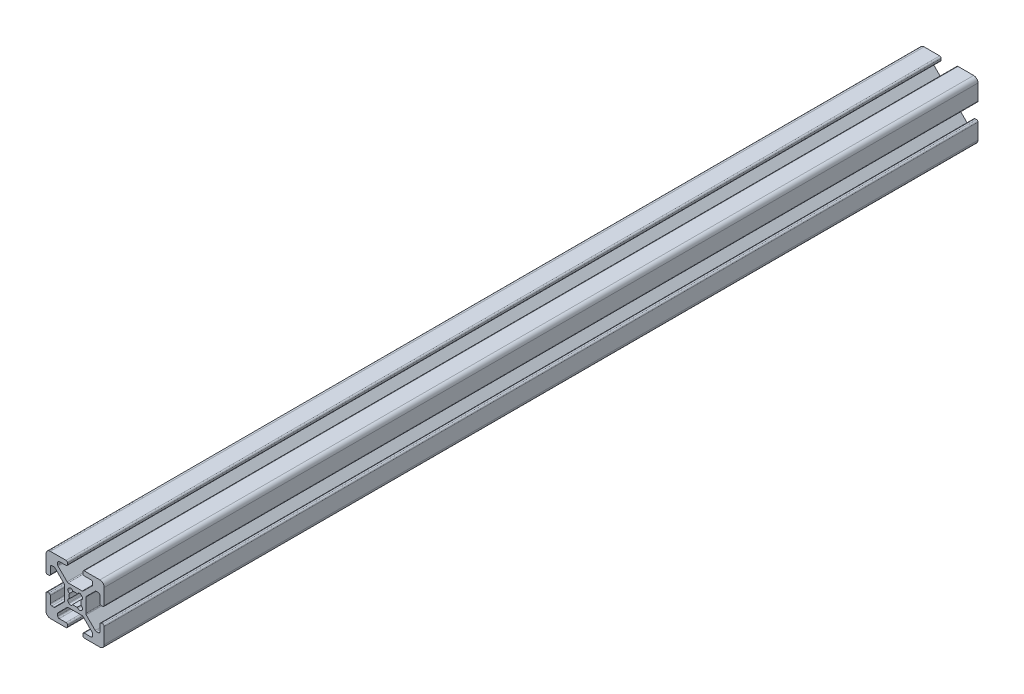
from build123d import *

# Parameters (mm, degrees)
EXTRUDE1_DEPTH = 300


with BuildPart() as part:
    # Sketch1 → Extrude1 (new body)
    with BuildSketch(Plane.XY):
        with BuildLine():
            Line((9.492, 2.63), (9.008, 2.63))
            ThreePointArc((9.008, 2.63), (8.648789755, 2.778789755), (8.5, 3.138))
            Line((8.5, 3.138), (8.5, 5.487))
            ThreePointArc((8.5, 5.487), (8.351210245, 5.846210245), (7.992, 5.995))
            Line((7.992, 5.995), (7.266080661, 5.995))
            ThreePointArc((7.266080661, 5.995), (7.071677478, 5.956330803), (6.906870417, 5.846210245))
            Line((6.906870417, 5.846210245), (3.803789755, 2.743129583))
            ThreePointArc((3.803789755, 2.743129583), (3.693669197, 2.578322522), (3.655, 2.383919339))
            Line((3.655, 2.383919339), (3.655, -2.383919339))
            ThreePointArc((3.655, -2.383919339), (3.693669197, -2.578322522), (3.803789755, -2.743129583))
            Line((3.803789755, -2.743129583), (6.906870417, -5.846210245))
            ThreePointArc((6.906870417, -5.846210245), (7.071677478, -5.956330803), (7.266080661, -5.995))
            Line((7.266080661, -5.995), (7.992, -5.995))
            ThreePointArc((7.992, -5.995), (8.351210245, -5.846210245), (8.5, -5.487))
            Line((8.5, -5.487), (8.5, -3.138))
            ThreePointArc((8.5, -3.138), (8.648789755, -2.778789755), (9.008, -2.63))
            Line((9.008, -2.63), (9.492, -2.63))
            ThreePointArc((9.492, -2.63), (9.851210245, -2.778789755), (10, -3.138))
            Line((10, -3.138), (10, -8.5))
            ThreePointArc((10, -8.5), (9.560660172, -9.560660172), (8.5, -10))
            Line((8.5, -10), (3.138, -10))
            ThreePointArc((3.138, -10), (2.778789755, -9.851210245), (2.63, -9.492))
            Line((2.63, -9.492), (2.63, -9.008))
            ThreePointArc((2.63, -9.008), (2.778789755, -8.648789755), (3.138, -8.5))
            Line((3.138, -8.5), (5.487, -8.5))
            ThreePointArc((5.487, -8.5), (5.846210245, -8.351210245), (5.995, -7.992))
            Line((5.995, -7.992), (5.995, -7.266080661))
            ThreePointArc((5.995, -7.266080661), (5.956330803, -7.071677478), (5.846210245, -6.906870417))
            Line((5.846210245, -6.906870417), (2.743129583, -3.803789755))
            ThreePointArc((2.743129583, -3.803789755), (2.578322522, -3.693669197), (2.383919339, -3.655))
            Line((2.383919339, -3.655), (-2.383919339, -3.655))
            ThreePointArc((-2.383919339, -3.655), (-2.578322522, -3.693669197), (-2.743129583, -3.803789755))
            Line((-2.743129583, -3.803789755), (-5.846210245, -6.906870417))
            ThreePointArc((-5.846210245, -6.906870417), (-5.956330803, -7.071677478), (-5.995, -7.266080661))
            Line((-5.995, -7.266080661), (-5.995, -7.992))
            ThreePointArc((-5.995, -7.992), (-5.846210245, -8.351210245), (-5.487, -8.5))
            Line((-5.487, -8.5), (-3.138, -8.5))
            ThreePointArc((-3.138, -8.5), (-2.778789755, -8.648789755), (-2.63, -9.008))
            Line((-2.63, -9.008), (-2.63, -9.492))
            ThreePointArc((-2.63, -9.492), (-2.778789755, -9.851210245), (-3.138, -10))
            Line((-3.138, -10), (-8.5, -10))
            ThreePointArc((-8.5, -10), (-9.560660172, -9.560660172), (-10, -8.5))
            Line((-10, -8.5), (-10, -3.138))
            ThreePointArc((-10, -3.138), (-9.851210245, -2.778789755), (-9.492, -2.63))
            Line((-9.492, -2.63), (-9.008, -2.63))
            ThreePointArc((-9.008, -2.63), (-8.648789755, -2.778789755), (-8.5, -3.138))
            Line((-8.5, -3.138), (-8.5, -5.487))
            ThreePointArc((-8.5, -5.487), (-8.351210245, -5.846210245), (-7.992, -5.995))
            Line((-7.992, -5.995), (-7.266080661, -5.995))
            ThreePointArc((-7.266080661, -5.995), (-7.071677478, -5.956330803), (-6.906870417, -5.846210245))
            Line((-6.906870417, -5.846210245), (-3.803789755, -2.743129583))
            ThreePointArc((-3.803789755, -2.743129583), (-3.693669197, -2.578322522), (-3.655, -2.383919339))
            Line((-3.655, -2.383919339), (-3.655, 2.383919339))
            ThreePointArc((-3.655, 2.383919339), (-3.693669197, 2.578322522), (-3.803789755, 2.743129583))
            Line((-3.803789755, 2.743129583), (-6.906870417, 5.846210245))
            ThreePointArc((-6.906870417, 5.846210245), (-7.071677478, 5.956330803), (-7.266080661, 5.995))
            Line((-7.266080661, 5.995), (-7.992, 5.995))
            ThreePointArc((-7.992, 5.995), (-8.351210245, 5.846210245), (-8.5, 5.487))
            Line((-8.5, 5.487), (-8.5, 3.138))
            ThreePointArc((-8.5, 3.138), (-8.648789755, 2.778789755), (-9.008, 2.63))
            Line((-9.008, 2.63), (-9.492, 2.63))
            ThreePointArc((-9.492, 2.63), (-9.851210245, 2.778789755), (-10, 3.138))
            Line((-10, 3.138), (-10, 8.5))
            ThreePointArc((-10, 8.5), (-9.560660172, 9.560660172), (-8.5, 10))
            Line((-8.5, 10), (-3.138, 10))
            ThreePointArc((-3.138, 10), (-2.778789755, 9.851210245), (-2.63, 9.492))
            Line((-2.63, 9.492), (-2.63, 9.008))
            ThreePointArc((-2.63, 9.008), (-2.778789755, 8.648789755), (-3.138, 8.5))
            Line((-3.138, 8.5), (-5.487, 8.5))
            ThreePointArc((-5.487, 8.5), (-5.846210245, 8.351210245), (-5.995, 7.992))
            Line((-5.995, 7.992), (-5.995, 7.266080661))
            ThreePointArc((-5.995, 7.266080661), (-5.956330803, 7.071677478), (-5.846210245, 6.906870417))
            Line((-5.846210245, 6.906870417), (-2.743129583, 3.803789755))
            ThreePointArc((-2.743129583, 3.803789755), (-2.578322522, 3.693669197), (-2.383919339, 3.655))
            Line((-2.383919339, 3.655), (2.383919339, 3.655))
            ThreePointArc((2.383919339, 3.655), (2.578322522, 3.693669197), (2.743129583, 3.803789755))
            Line((2.743129583, 3.803789755), (5.846210245, 6.906870417))
            ThreePointArc((5.846210245, 6.906870417), (5.956330803, 7.071677478), (5.995, 7.266080661))
            Line((5.995, 7.266080661), (5.995, 7.992))
            ThreePointArc((5.995, 7.992), (5.846210245, 8.351210245), (5.487, 8.5))
            Line((5.487, 8.5), (3.138, 8.5))
            ThreePointArc((3.138, 8.5), (2.778789755, 8.648789755), (2.63, 9.008))
            Line((2.63, 9.008), (2.63, 9.492))
            ThreePointArc((2.63, 9.492), (2.778789755, 9.851210245), (3.138, 10))
            Line((3.138, 10), (8.5, 10))
            ThreePointArc((8.5, 10), (9.560660172, 9.560660172), (10, 8.5))
            Line((10, 8.5), (10, 3.138))
            ThreePointArc((10, 3.138), (9.851210245, 2.778789755), (9.492, 2.63))
        make_face()
        with BuildLine():
            Line((2.124900844, -2.304505966), (2.304505966, -2.124900844))
            ThreePointArc((2.304505966, -2.124900844), (2.505938017, -1.356467811), (1.935133506, -0.803976718))
            ThreePointArc((1.935133506, -0.803976718), (2.0955, 0), (1.935133506, 0.803976718))
            ThreePointArc((1.935133506, 0.803976718), (2.505938017, 1.356467811), (2.304505966, 2.124900844))
            Line((2.304505966, 2.124900844), (2.124900844, 2.304505966))
            ThreePointArc((2.124900844, 2.304505966), (1.356467811, 2.505938017), (0.803976718, 1.935133506))
            ThreePointArc((0.803976718, 1.935133506), (0, 2.0955), (-0.803976718, 1.935133506))
            ThreePointArc((-0.803976718, 1.935133506), (-1.356467811, 2.505938017), (-2.124900844, 2.304505966))
            Line((-2.124900844, 2.304505966), (-2.304505966, 2.124900844))
            ThreePointArc((-2.304505966, 2.124900844), (-2.505938017, 1.356467811), (-1.935133506, 0.803976718))
            ThreePointArc((-1.935133506, 0.803976718), (-2.0955, 0), (-1.935133506, -0.803976718))
            ThreePointArc((-1.935133506, -0.803976718), (-2.505938017, -1.356467811), (-2.304505966, -2.124900844))
            Line((-2.304505966, -2.124900844), (-2.124900844, -2.304505966))
            ThreePointArc((-2.124900844, -2.304505966), (-1.356467811, -2.505938017), (-0.803976718, -1.935133506))
            ThreePointArc((-0.803976718, -1.935133506), (0, -2.0955), (0.803976718, -1.935133506))
            ThreePointArc((0.803976718, -1.935133506), (1.356467811, -2.505938017), (2.124900844, -2.304505966))
        make_face(mode=Mode.SUBTRACT)
    extrude(amount=-EXTRUDE1_DEPTH)


solid = part.part
